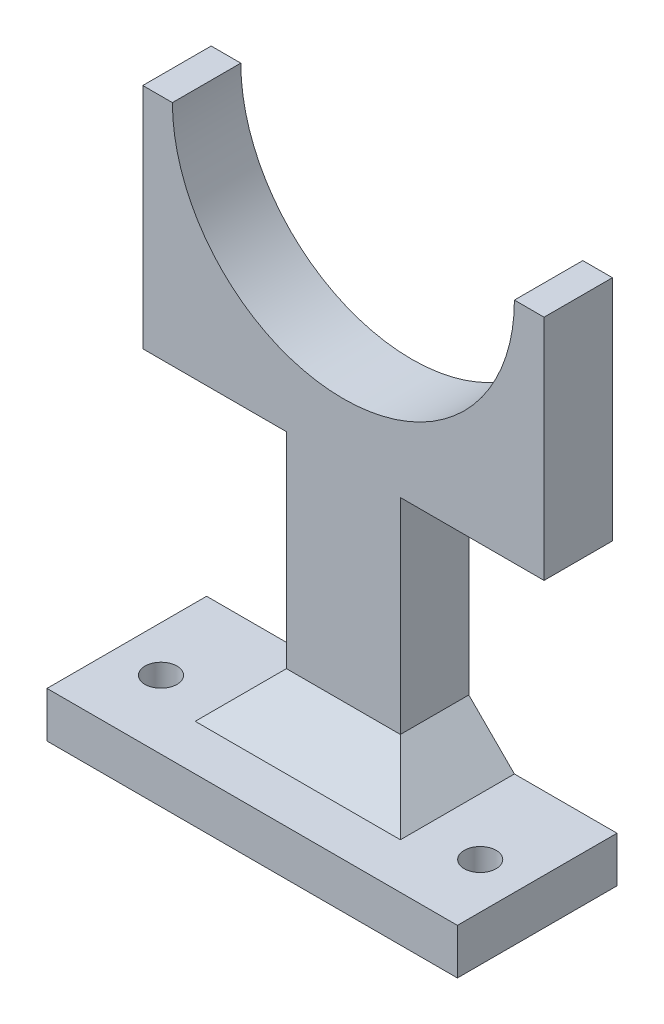
from build123d import *

# Parameters (mm, degrees)
SKETCH_1_W          = 25
SKETCH_1_H          = 55
SKETCH_1_W_2        = 90
SKETCH_1_H_2        = 10
EXTRUDE_1_DEPTH     = 15
SKETCH_2_W          = 90
SKETCH_2_H          = 10
EXTRUDE_2_DEPTH     = 20
CHAMFER_4_SIZE      = 10
SKETCH_4_R          = 2
CUT_EXTRUDE_1_DEPTH = 11
SKETCH_5_R          = 3.5
CUT_EXTRUDE_2_DEPTH = 7


with BuildPart() as part:
    # 草圖1 → 填料-伸長1 (new body)
    with BuildSketch(Plane.XY):
        with BuildLine():
            Line((-62.370495495, 24.5), (-30.870495495, 24.5))
            Line((-30.870495495, 24.5), (-5.870495495, 24.5))
            Line((-5.870495495, 24.5), (25.629504505, 24.5))
            Line((25.629504505, 24.5), (25.629504505, 74.5))
            Line((25.629504505, 74.5), (19.129504505, 74.5))
            ThreePointArc((19.129504505, 74.5), (-18.370495495, 37), (-55.870495495, 74.5))
            Line((-55.870495495, 74.5), (-62.370495495, 74.5))
            Line((-62.370495495, 74.5), (-62.370495495, 24.5))
        make_face()
        with Locations((-18.370495495, -3)):
            Rectangle(SKETCH_1_W, SKETCH_1_H)
        with Locations((-18.370495495, -35.5)):
            Rectangle(SKETCH_1_W_2, SKETCH_1_H_2)
    extrude(amount=EXTRUDE_1_DEPTH)

    # 草圖2 → 填料-伸長2 (add)
    with BuildSketch(Plane.XY.offset(15)):
        with Locations((-18.370495495, -35.5)):
            Rectangle(SKETCH_2_W, SKETCH_2_H)
    extrude(amount=EXTRUDE_2_DEPTH)

    # 導角4
    chamfer_4_edges = [part.edges().sort_by_distance(p)[0] for p in [
        (-5.870495495, -30.5, 7.5),
        (-30.870495495, -30.5, 7.5),
        (-18.370495495, -30.5, 15),
    ]]
    chamfer(chamfer_4_edges, length=CHAMFER_4_SIZE)

    # 草圖4 → 除料-伸長1 (cut, through all)
    with BuildSketch(Plane(origin=(0, -30.5, 0), x_dir=(1, 0, 0), z_dir=(0, 1, 0))):
        with Locations((-53.370495495, -20)):
            Circle(SKETCH_4_R)
        with Locations((16.629504505, -20)):
            Circle(SKETCH_4_R)
    extrude(amount=-CUT_EXTRUDE_1_DEPTH, mode=Mode.SUBTRACT)

    # 草圖5 → 除料-伸長2 (cut)
    with BuildSketch(Plane(origin=(0, -30.5, 0), x_dir=(1, 0, 0), z_dir=(0, 1, 0))):
        with Locations((-53.370495495, -20)):
            Circle(SKETCH_5_R)
        with Locations((16.629504505, -20)):
            Circle(SKETCH_5_R)
    extrude(amount=-CUT_EXTRUDE_2_DEPTH, mode=Mode.SUBTRACT)


solid = part.part
